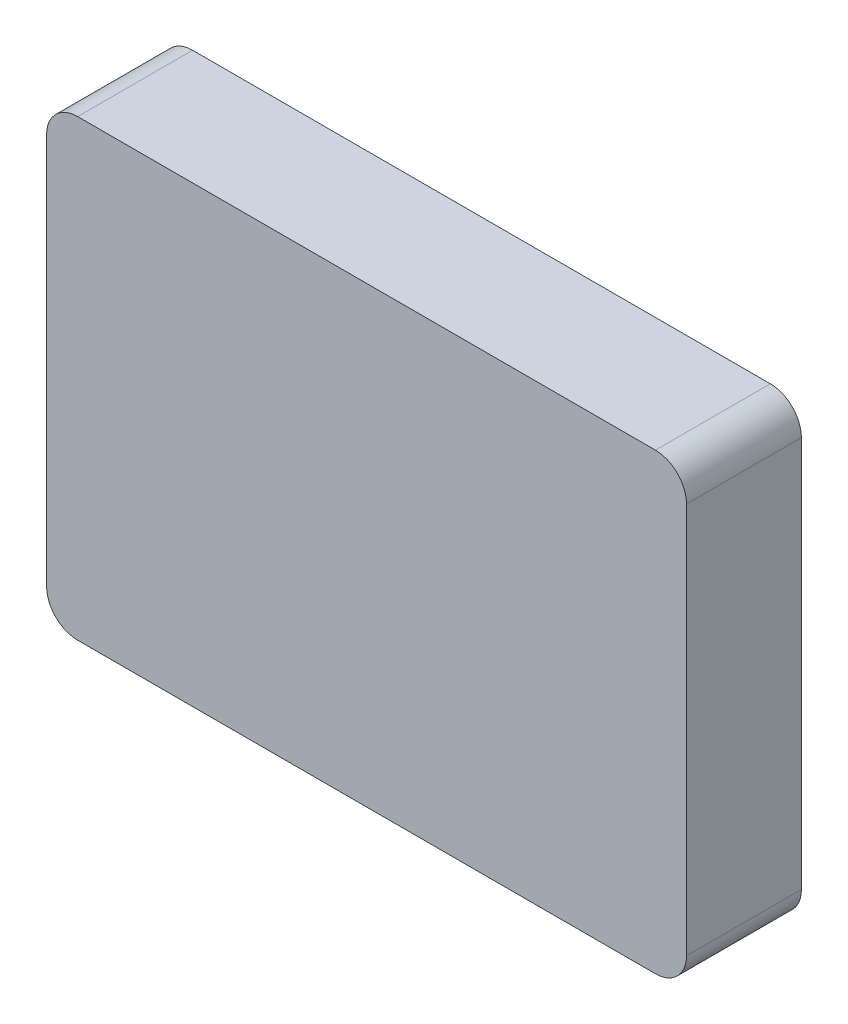
from build123d import *

# Parameters (mm, degrees)
DODANIE_WYCI_GNI_CIE6_DEPTH = 18.5
SKORUPA2_T                  = -2
FILLET1_R                   = 5


with BuildPart() as part:
    # Szkic5 → Dodanie-wyciągnięcie6 (new body)
    with BuildSketch(Plane.XY):
        Polygon((38, 36.5), (51.5, 36.5), (51.5, -36.5), (-51.5, -36.5), (-51.5, 36.5), (-5.5, 36.5), align=None)
    extrude(amount=-DODANIE_WYCI_GNI_CIE6_DEPTH)

    # Skorupa2
    skorupa2_openings = [part.faces().sort_by_distance(p)[0] for p in [
        (0, 0, -18.5),
    ]]
    offset(amount=SKORUPA2_T, openings=skorupa2_openings, kind=Kind.INTERSECTION)

    # Fillet1
    fillet1_edges = [part.edges().sort_by_distance(p)[0] for p in [
        (51.5, -36.5, -9.25),
        (-51.5, -36.5, -9.25),
        (-51.5, 36.5, -9.25),
        (51.5, 36.5, -9.25),
    ]]
    fillet(fillet1_edges, radius=FILLET1_R)


solid = part.part
